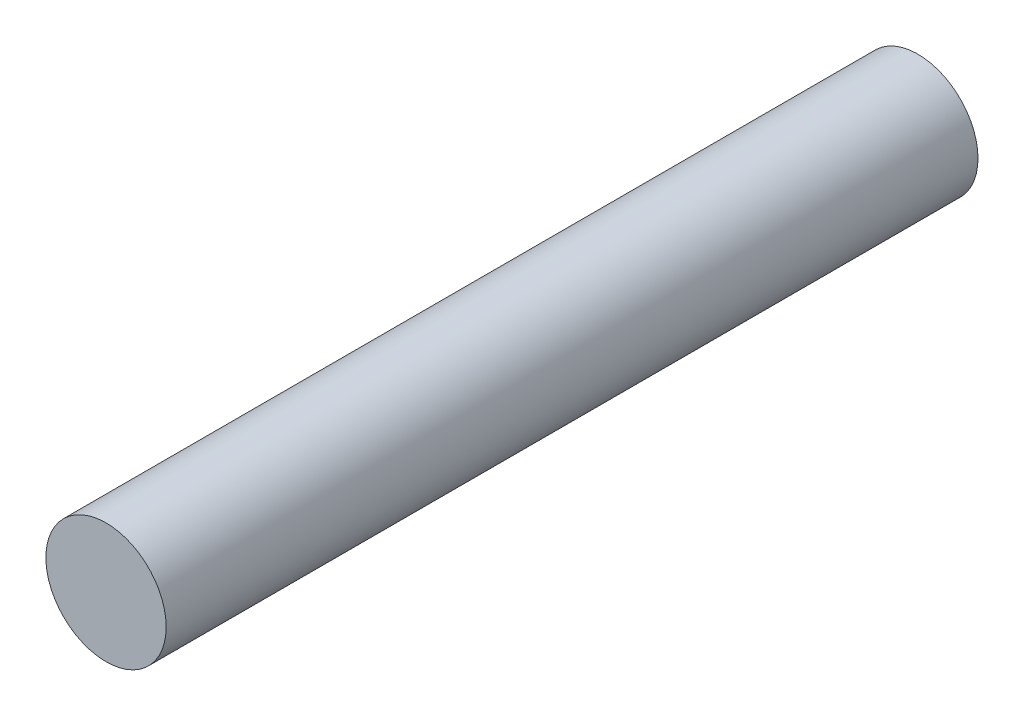
from build123d import *

# Parameters (mm, degrees)
SKETCH1_R           = 3.175
BOSS_EXTRUDE1_DEPTH = 42.8625


with BuildPart() as part:
    # Sketch1 → Boss-Extrude1 (new body)
    with BuildSketch(Plane.XY):
        Circle(SKETCH1_R)
    extrude(amount=BOSS_EXTRUDE1_DEPTH)


solid = part.part
